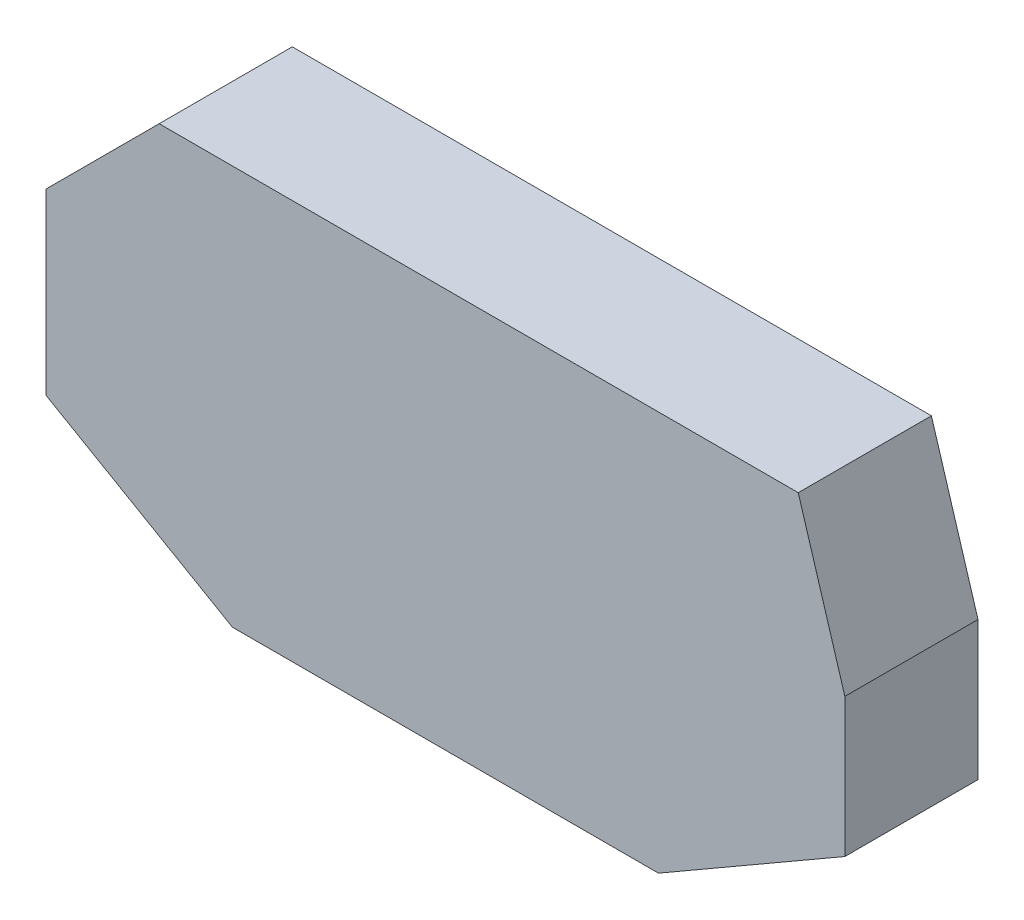
from build123d import *

# Parameters (mm, degrees)
BOSS_EXTRU_6_DEPTH = 20


with BuildPart() as part:
    # Esquisse5 → Boss.-Extru.6 (new body)
    with BuildSketch(Plane.XY):
        Polygon((-60, 13), (-43, 30), (53, 30), (60, 7), (60, -13.834192463), (32, -30), (-32, -30), (-60, -13.834192463), align=None)
    extrude(amount=BOSS_EXTRU_6_DEPTH)


solid = part.part
